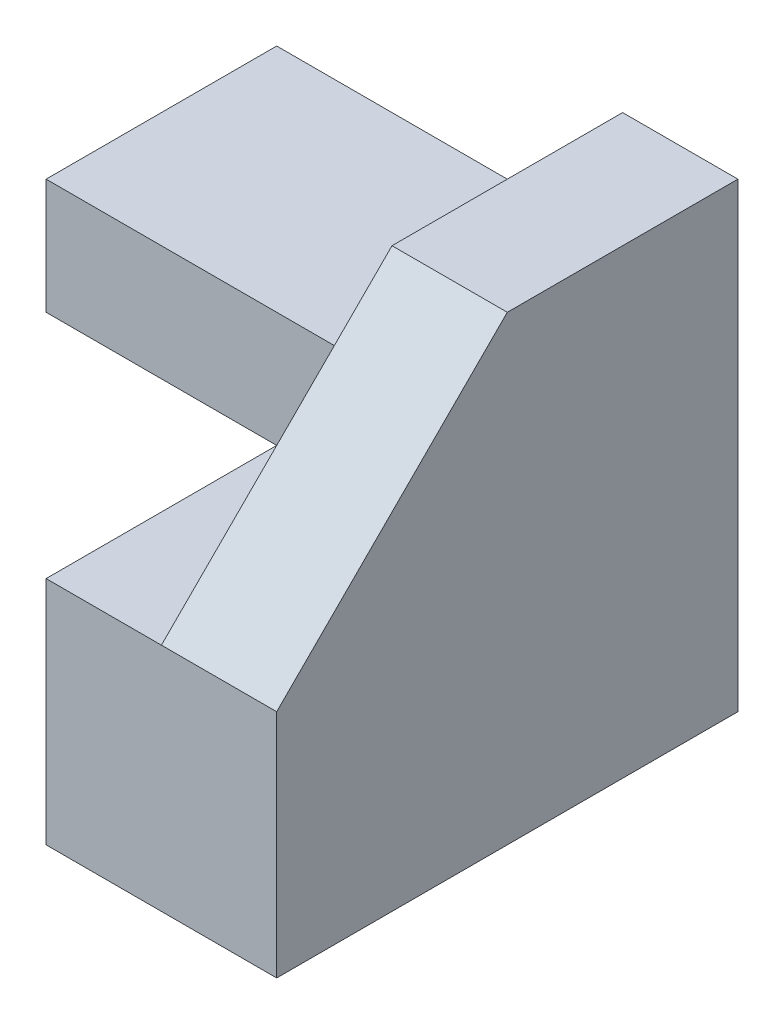
from build123d import *

# Parameters (mm, degrees)
SKETCH2_W                = 2
SKETCH2_H                = 2
BOSS_EXTRUDE1_DEPTH      = 4
BOSS_EXTRUDE2_DEPTH      = 2
BOSS_EXTRUDE2_DEPTH_BACK = 1
SKETCH4_W                = 1
SKETCH4_H                = 2
BOSS_EXTRUDE3_DEPTH      = 2
BOSS_EXTRUDE4_DEPTH      = 1


with BuildPart() as part:
    # Sketch2 → Boss-Extrude1 (new body)
    with BuildSketch(Plane.XY):
        with Locations((1, 1)):
            Rectangle(SKETCH2_W, SKETCH2_H)
    extrude(amount=BOSS_EXTRUDE1_DEPTH)

    # Sketch3 → Boss-Extrude2 (add, two sides)
    with BuildSketch(Plane.ZY) as boss_extrude2_sk:
        Polygon((0, 1), (0, 3), (2, 3), (2, 2), align=None)
    extrude(amount=BOSS_EXTRUDE2_DEPTH)
    extrude(boss_extrude2_sk.sketch, amount=-BOSS_EXTRUDE2_DEPTH_BACK)

    # Sketch4 → Boss-Extrude3 (add)
    with BuildSketch(Plane(origin=(0, 2, 0), x_dir=(1, 0, 0), z_dir=(0, 1, 0))):
        with Locations((1.5, -1)):
            Rectangle(SKETCH4_W, SKETCH4_H)
    extrude(amount=BOSS_EXTRUDE3_DEPTH)

    # Sketch5 → Boss-Extrude4 (add)
    with BuildSketch(Plane(origin=(2, 0, 0), x_dir=(0, 0, -1), z_dir=(1, 0, 0))):
        Polygon((-2, 4), (-4, 2), (-2, 2), align=None)
    extrude(amount=-BOSS_EXTRUDE4_DEPTH)


solid = part.part
